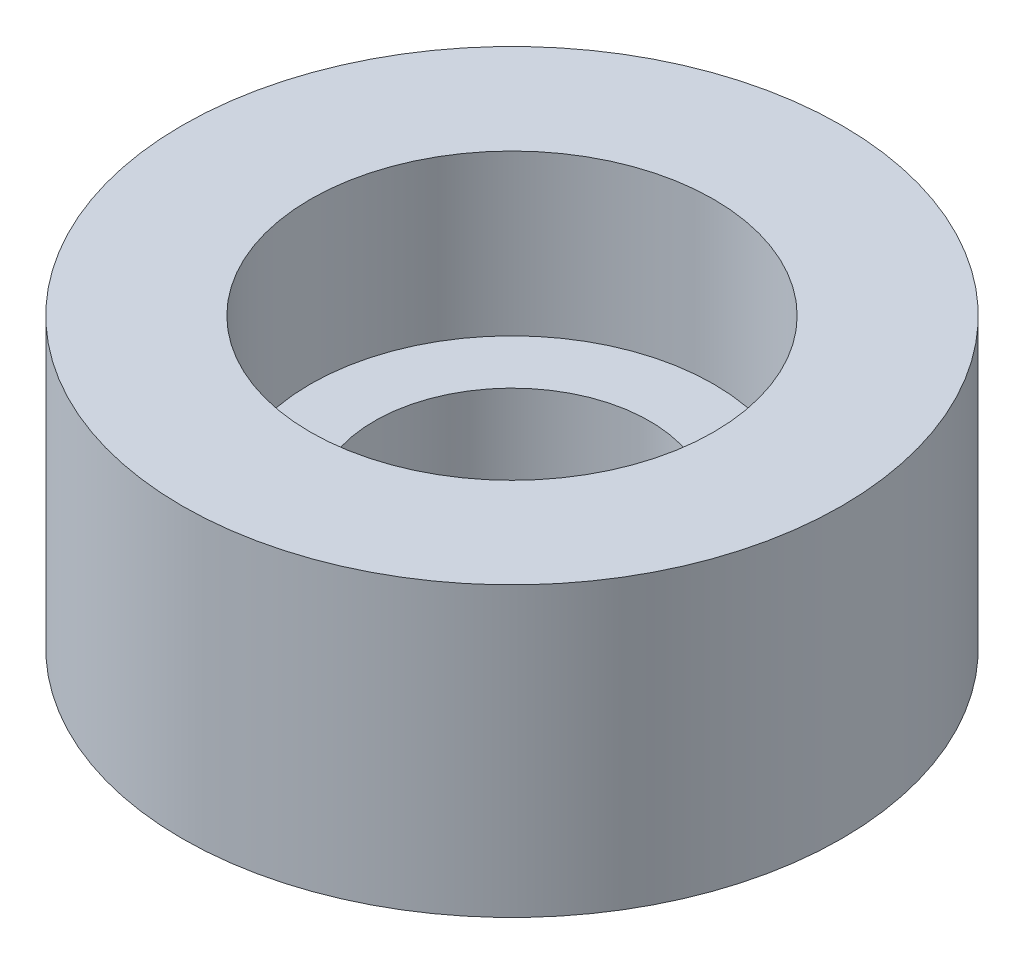
from build123d import *

# Parameters (mm, degrees)
SKETCH1_R           = 5.15
SKETCH1_R_2         = 3.15
EXTRUDE_THIN1_DEPTH = 4.5
SKETCH2_R           = 3.15
SKETCH2_R_2         = 2.15
BOSS_EXTRUDE1_DEPTH = 2


with BuildPart() as part:
    # Sketch1 → Extrude-Thin1 (new body)
    with BuildSketch(Plane(origin=(0, 0, 0), x_dir=(1, 0, 0), z_dir=(0, 1, 0))):
        Circle(SKETCH1_R)
        Circle(SKETCH1_R_2, mode=Mode.SUBTRACT)
    extrude(amount=EXTRUDE_THIN1_DEPTH)

    # Sketch2 → Boss-Extrude1 (add)
    with BuildSketch(Plane(origin=(0, 0, 0), x_dir=(1, 0, 0), z_dir=(0, 1, 0))):
        Circle(SKETCH2_R)
        Circle(SKETCH2_R_2, mode=Mode.SUBTRACT)
    extrude(amount=BOSS_EXTRUDE1_DEPTH)


solid = part.part
